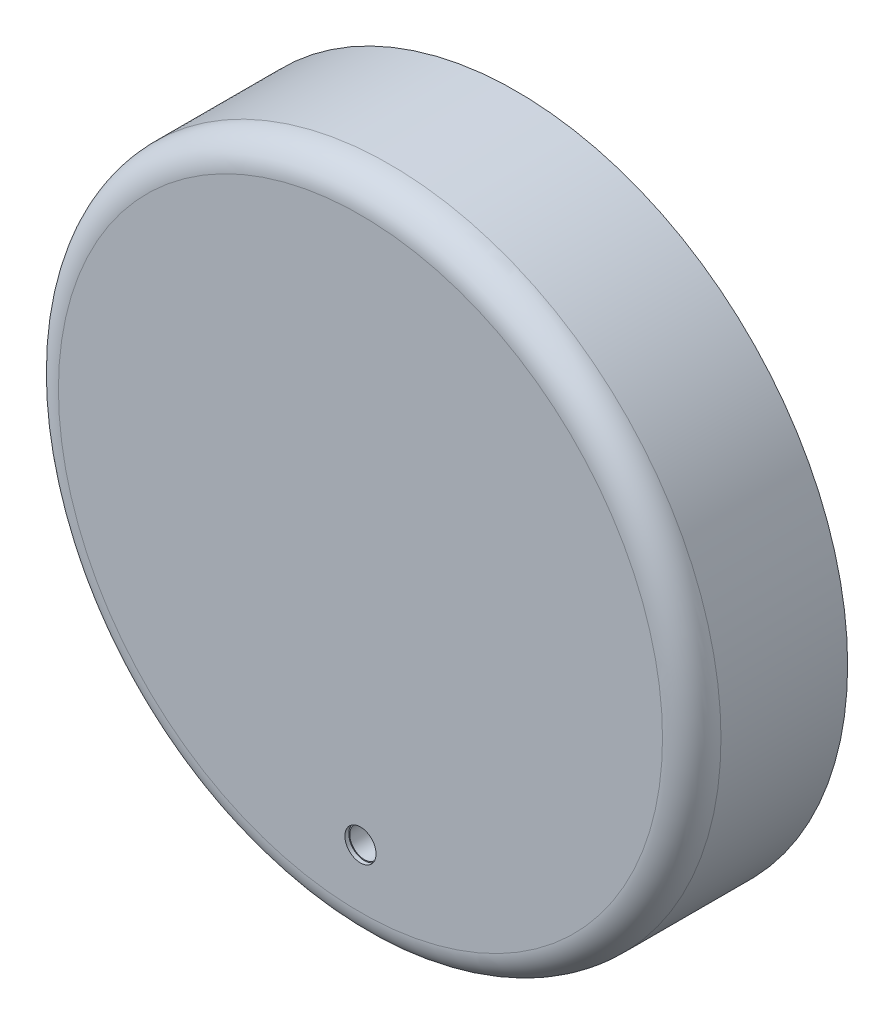
from build123d import *

# Parameters (mm, degrees)
SKETCH1_R           = 34
SKETCH1_R_2         = 31.5
BOSS_EXTRUDE1_DEPTH = 13
SKETCH2_R           = 34
BOSS_EXTRUDE2_DEPTH = 3
FILLET1_R           = 3
SKETCH3_R           = 2.5
SKETCH3_R_2         = 1.5
BOSS_EXTRUDE3_DEPTH = 10
SKETCH5_R           = 32.5
SKETCH5_R_2         = 31.5
CUT_EXTRUDE1_DEPTH  = 3
SKETCH6_R           = 1.6
CUT_EXTRUDE2_DEPTH  = 0.4
SKETCH7_R           = 1.5
CUT_EXTRUDE3_DEPTH  = 16.6


with BuildPart() as part:
    # Sketch1 → Boss-Extrude1 (new body)
    with BuildSketch(Plane.XY):
        Circle(SKETCH1_R)
        Circle(SKETCH1_R_2, mode=Mode.SUBTRACT)
    extrude(amount=BOSS_EXTRUDE1_DEPTH)

    # Sketch2 → Boss-Extrude2 (add)
    with BuildSketch(Plane.XY.offset(13)):
        Circle(SKETCH2_R)
    extrude(amount=BOSS_EXTRUDE2_DEPTH)

    # Fillet1
    fillet1_edges = [part.edges().sort_by_distance(p)[0] for p in [
        (-34, 0, 16),
    ]]
    fillet(fillet1_edges, radius=FILLET1_R)

    # Sketch3 → Boss-Extrude3 (add)
    with BuildSketch(Plane(origin=(0, 0, 13), x_dir=(-1, 0, 0), z_dir=(0, 0, -1))):
        with Locations((-20, 0)):
            Circle(SKETCH3_R)
        with Locations((-20, 0)):
            Circle(SKETCH3_R_2, mode=Mode.SUBTRACT)
        with Locations((20, 0)):
            Circle(SKETCH3_R)
        with Locations((20, 0)):
            Circle(SKETCH3_R_2, mode=Mode.SUBTRACT)
    extrude(amount=BOSS_EXTRUDE3_DEPTH)

    # Sketch5 → Cut-Extrude1 (cut)
    with BuildSketch(Plane(origin=(0, 0, 0), x_dir=(-1, 0, 0), z_dir=(0, 0, -1))):
        Circle(SKETCH5_R)
        Circle(SKETCH5_R_2, mode=Mode.SUBTRACT)
    extrude(amount=-CUT_EXTRUDE1_DEPTH, mode=Mode.SUBTRACT)

    # Sketch6 → Cut-Extrude2 (cut)
    with BuildSketch(Plane.XY.offset(16)):
        with Locations((0, -25)):
            Circle(SKETCH6_R)
    extrude(amount=-CUT_EXTRUDE2_DEPTH, mode=Mode.SUBTRACT)

    # Sketch7 → Cut-Extrude3 (cut, through all)
    with BuildSketch(Plane.XY.offset(15.6)):
        with Locations((0, -25)):
            Circle(SKETCH7_R)
    extrude(amount=-CUT_EXTRUDE3_DEPTH, mode=Mode.SUBTRACT)


solid = part.part
